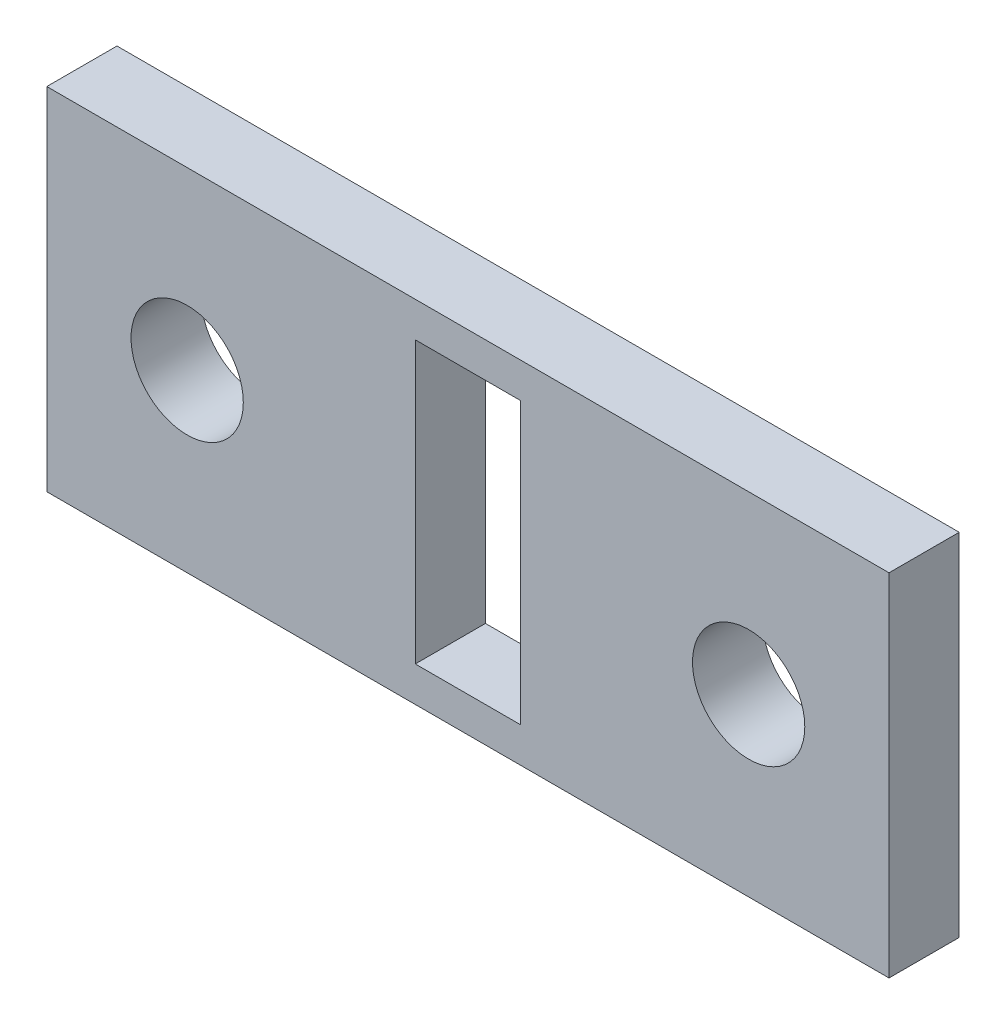
from build123d import *

# Parameters (mm, degrees)
SKETCH1_W           = 24
SKETCH1_H           = 10
BOSS_EXTRUDE1_DEPTH = 2
SKETCH2_R           = 1.6
CUT_EXTRUDE1_DEPTH  = 2
SKETCH3_W           = 3
SKETCH3_H           = 8
CUT_EXTRUDE2_DEPTH  = 2


with BuildPart() as part:
    # Sketch1 → Boss-Extrude1 (new body)
    with BuildSketch(Plane.XY):
        with Locations((12, 5)):
            Rectangle(SKETCH1_W, SKETCH1_H)
    extrude(amount=BOSS_EXTRUDE1_DEPTH)

    # Sketch2 → Cut-Extrude1 (cut)
    with BuildSketch(Plane.XY.offset(2)):
        with Locations((4, 5)):
            Circle(SKETCH2_R)
        with Locations((20, 5)):
            Circle(SKETCH2_R)
    extrude(amount=-CUT_EXTRUDE1_DEPTH, mode=Mode.SUBTRACT)

    # Sketch3 → Cut-Extrude2 (cut)
    with BuildSketch(Plane.XY.offset(2)):
        with Locations((12, 5)):
            Rectangle(SKETCH3_W, SKETCH3_H)
    extrude(amount=-CUT_EXTRUDE2_DEPTH, mode=Mode.SUBTRACT)


solid = part.part
